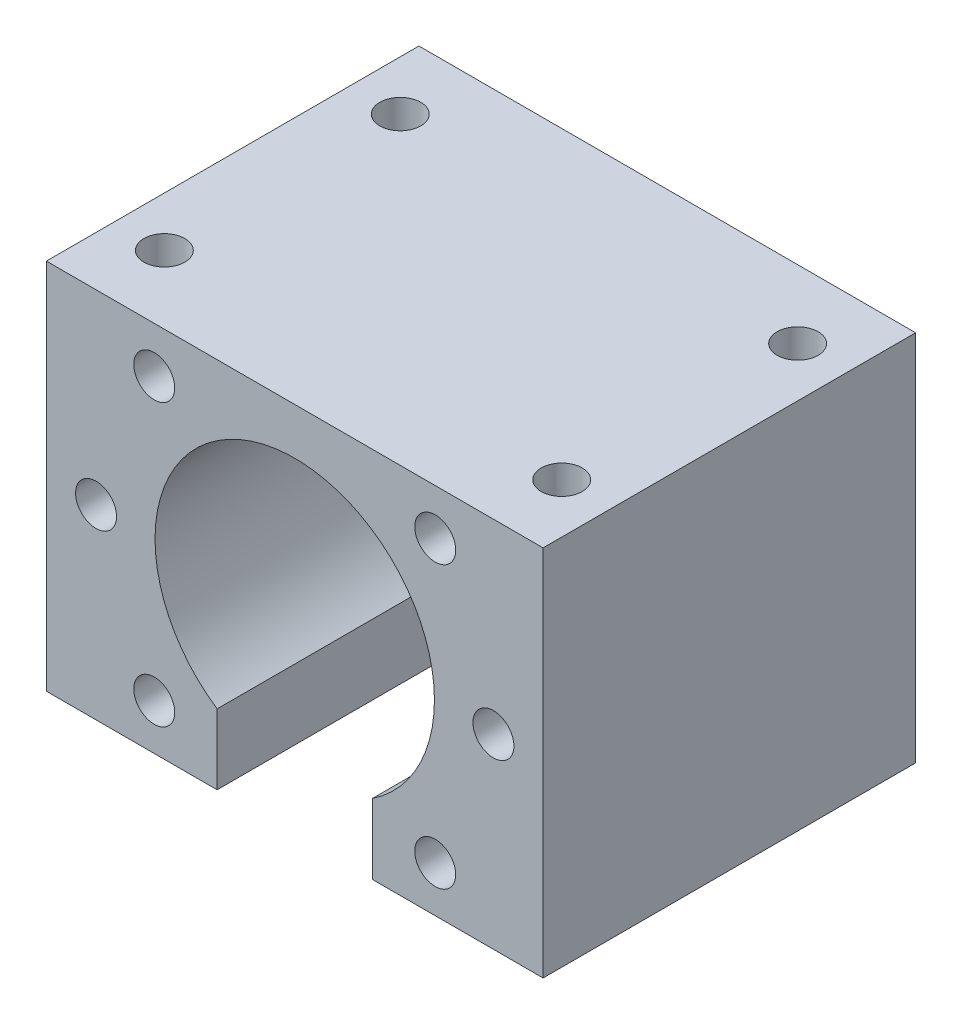
from build123d import *

# Parameters (mm, degrees)
IZIM1_W                            = 40
IZIM1_H                            = 30
Y_KSEKLIK_EKSTR_ZYON1_DEPTH        = 15
KES_EKSTR_ZYON1_DEPTH              = 30
M4_TAPA_I_IN_Z_VANA_MATKAB_1_D     = 3.3
M4_TAPA_I_IN_Z_VANA_MATKAB_1_DEPTH = 15
M4_TAPA_I_IN_Z_VANA_MATKAB_1_TIP   = 0.991420021
M4_TAPA_I_IN_Z_VANA_MATKAB_3_D     = 3.3
M4_TAPA_I_IN_Z_VANA_MATKAB_3_DEPTH = 13
M4_TAPA_I_IN_Z_VANA_MATKAB_3_TIP   = 0.991420021


with BuildPart() as part:
    # Çizim1 → Yükseklik-Ekstrüzyon1 (new body, symmetric)
    with BuildSketch(Plane.XY):
        Rectangle(IZIM1_W, IZIM1_H)
    extrude(amount=Y_KSEKLIK_EKSTR_ZYON1_DEPTH, both=True)

    # Çizim2 → Kes-Ekstrüzyon1 (cut)
    with BuildSketch(Plane.XY.offset(15)):
        with BuildLine():
            Line((-6.25, -15), (-6.25, -9.354143467))
            ThreePointArc((-6.25, -9.354143467), (0, 11.25), (6.25, -9.354143467))
            Line((6.25, -9.354143467), (6.25, -15))
            Line((6.25, -15), (-6.25, -15))
        make_face()
    extrude(amount=-KES_EKSTR_ZYON1_DEPTH, mode=Mode.SUBTRACT)

    # M4 Tapa için Zıvana matkabı1
    with Locations(Plane(origin=(-11.313708499, 11.313708499, 15), x_dir=(1, 0, 0), z_dir=(0, 0, 1))):
        with Locations((0, 0), (-4.686291501, -11.313708499), (0, -22.627416998), (22.627416998, -22.627416998), (27.313708499, -11.313708499), (22.627416998, 0)):
            Hole(M4_TAPA_I_IN_Z_VANA_MATKAB_1_D / 2, depth=M4_TAPA_I_IN_Z_VANA_MATKAB_1_DEPTH)
            with Locations((0, 0, -(M4_TAPA_I_IN_Z_VANA_MATKAB_1_DEPTH + M4_TAPA_I_IN_Z_VANA_MATKAB_1_TIP / 2))):  # 118° drill point
                Cone(0, M4_TAPA_I_IN_Z_VANA_MATKAB_1_D / 2, M4_TAPA_I_IN_Z_VANA_MATKAB_1_TIP, mode=Mode.SUBTRACT)

    # M4 Tapa için Zıvana matkabı3
    with Locations(Plane(origin=(-16, 15, -9.5), x_dir=(1, 0, 0), z_dir=(0, 1, 0))):
        with Locations((0, 0), (0, -19), (32, 0), (32, -19)):
            Hole(M4_TAPA_I_IN_Z_VANA_MATKAB_3_D / 2, depth=M4_TAPA_I_IN_Z_VANA_MATKAB_3_DEPTH)
            with Locations((0, 0, -(M4_TAPA_I_IN_Z_VANA_MATKAB_3_DEPTH + M4_TAPA_I_IN_Z_VANA_MATKAB_3_TIP / 2))):  # 118° drill point
                Cone(0, M4_TAPA_I_IN_Z_VANA_MATKAB_3_D / 2, M4_TAPA_I_IN_Z_VANA_MATKAB_3_TIP, mode=Mode.SUBTRACT)


solid = part.part
